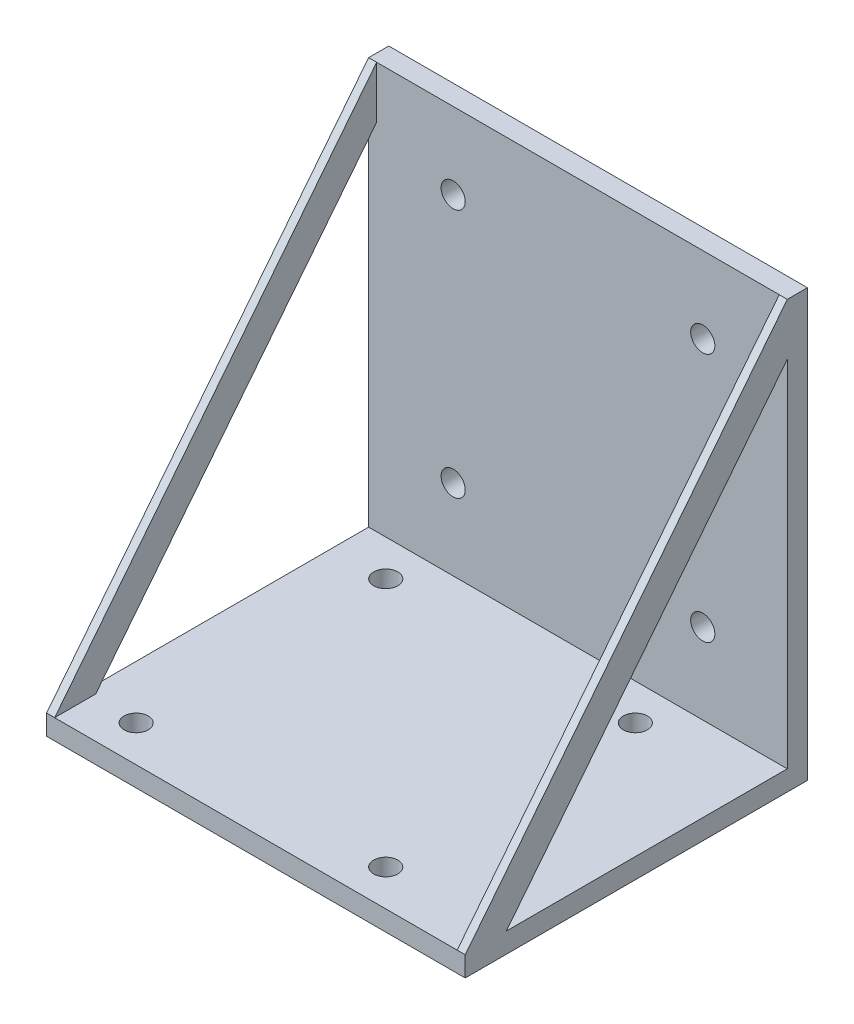
from build123d import *

# Parameters (mm, degrees)
SKETCH1_R           = 1.5
BOSS_EXTRUDE1_DEPTH = 2.5
SKETCH2_W           = 50
SKETCH2_H           = 2.5
BOSS_EXTRUDE2_DEPTH = 40
SKETCH3_R           = 1.5
CUT_EXTRUDE1_DEPTH  = 40
BOSS_EXTRUDE3_DEPTH = 1


with BuildPart() as part:
    # Sketch1 → Boss-Extrude1 (new body)
    with BuildSketch(Plane.XY):
        Polygon((-25, -25), (-25, 25), (25, 25), (25, -25), (25, -28), (-25, -28), align=None)
        with Locations((-15.5, 15.5)):
            Circle(SKETCH1_R, mode=Mode.SUBTRACT)
        with Locations((15.5, 15.5)):
            Circle(SKETCH1_R, mode=Mode.SUBTRACT)
        with Locations((15.5, -15.5)):
            Circle(SKETCH1_R, mode=Mode.SUBTRACT)
        with Locations((-15.5, -15.5)):
            Circle(SKETCH1_R, mode=Mode.SUBTRACT)
    extrude(amount=BOSS_EXTRUDE1_DEPTH)

    # Sketch2 → Boss-Extrude2 (add)
    with BuildSketch(Plane.XY.offset(2.5)):
        with Locations((0, -26.75)):
            Rectangle(SKETCH2_W, SKETCH2_H)
    extrude(amount=BOSS_EXTRUDE2_DEPTH)

    # Sketch3 → Cut-Extrude1 (cut)
    with BuildSketch(Plane(origin=(0, -25.5, 0), x_dir=(1, 0, 0), z_dir=(0, 1, 0))):
        with Locations((-19.375, -7)):
            Circle(SKETCH3_R)
        with Locations((11.625, -7)):
            Circle(SKETCH3_R)
        with Locations((11.625, -38)):
            Circle(SKETCH3_R)
        with Locations((-19.375, -38)):
            Circle(SKETCH3_R)
    extrude(amount=-CUT_EXTRUDE1_DEPTH, mode=Mode.SUBTRACT)

    # Sketch5 → Boss-Extrude3 (add)
    with BuildSketch(Plane(origin=(25, 0, 0), x_dir=(0, 0, -1), z_dir=(1, 0, 0))):
        Polygon((-42.5, -25.5), (-2.5, 25), (0, 25), (0, 16.843145751), (0, -28), (-39.343145751, -28), (-42.5, -28), align=None)
        Polygon((-2.5, 18.557756602), (-37.397232952, -25.5), (-2.5, -25.5), align=None, mode=Mode.SUBTRACT)
    boss_extrude3 = extrude(amount=BOSS_EXTRUDE3_DEPTH)

    # Mirror1: Boss-Extrude3 across plane
    add(boss_extrude3.mirror(Plane(origin=(0, 0, 0), x_dir=(0, 0, 1), z_dir=(1, 0, 0))))


solid = part.part
